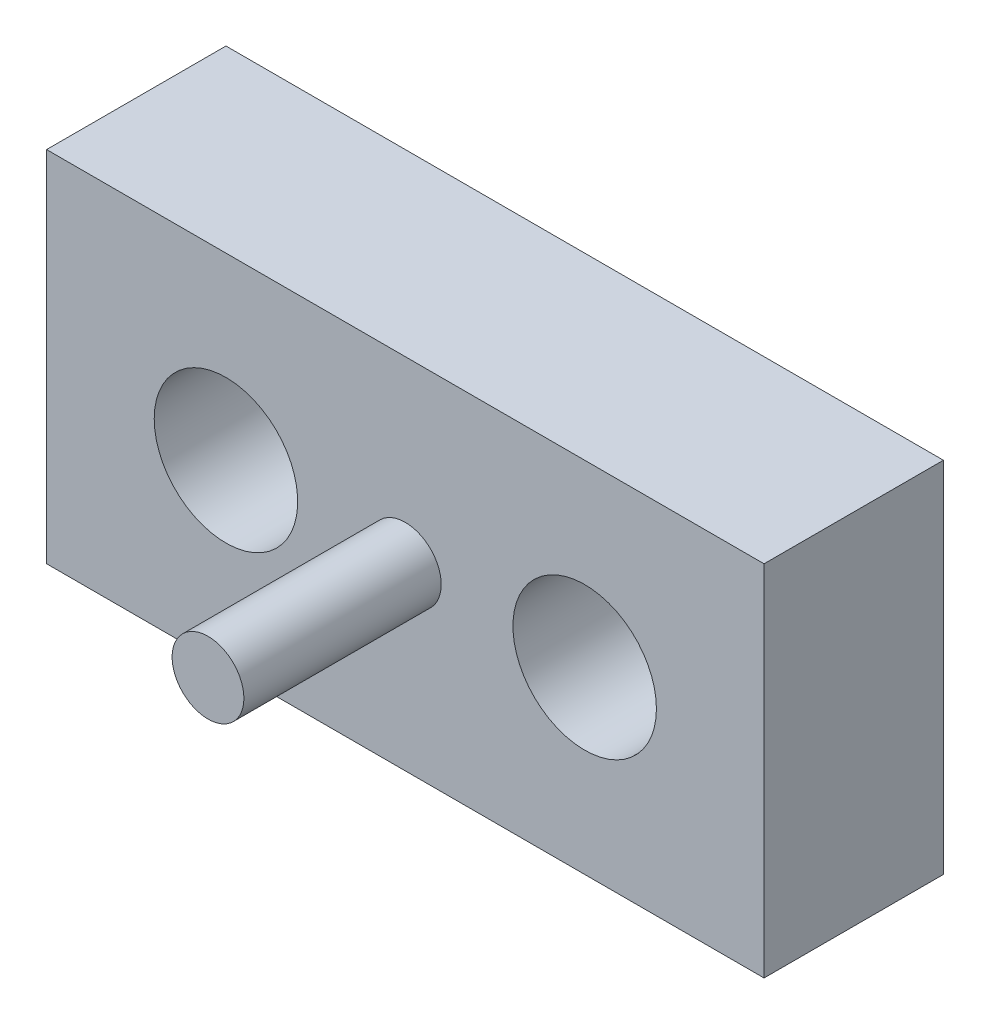
from build123d import *

# Parameters (mm, degrees)
SKETCH_1_W          = 20
SKETCH_1_H          = 10
SKETCH_1_R          = 1
EXTRUDE_1_DEPTH     = 5
SKETCH_2_R          = 1
EXTRUDE_2_DEPTH     = 5.5
SKETCH_4_R          = 2
CUT_EXTRUDE_2_DEPTH = 3


with BuildPart() as part:
    # 草图1 → 凸台-拉伸1 (new body)
    with BuildSketch(Plane.XY):
        Rectangle(SKETCH_1_W, SKETCH_1_H)
        with Locations((-5, 0)):
            Circle(SKETCH_1_R, mode=Mode.SUBTRACT)
        with Locations((5, 0)):
            Circle(SKETCH_1_R, mode=Mode.SUBTRACT)
    extrude(amount=EXTRUDE_1_DEPTH)

    # 草图2 → 凸台-拉伸2 (add)
    with BuildSketch(Plane.XY.offset(5)):
        Circle(SKETCH_2_R)
    extrude(amount=EXTRUDE_2_DEPTH)

    # 草图4 → 切除-拉伸2 (cut)
    with BuildSketch(Plane.XY.offset(5)):
        with Locations((5, 0)):
            Circle(SKETCH_4_R)
        with Locations((-5, 0)):
            Circle(SKETCH_4_R)
    extrude(amount=-CUT_EXTRUDE_2_DEPTH, mode=Mode.SUBTRACT)


solid = part.part
